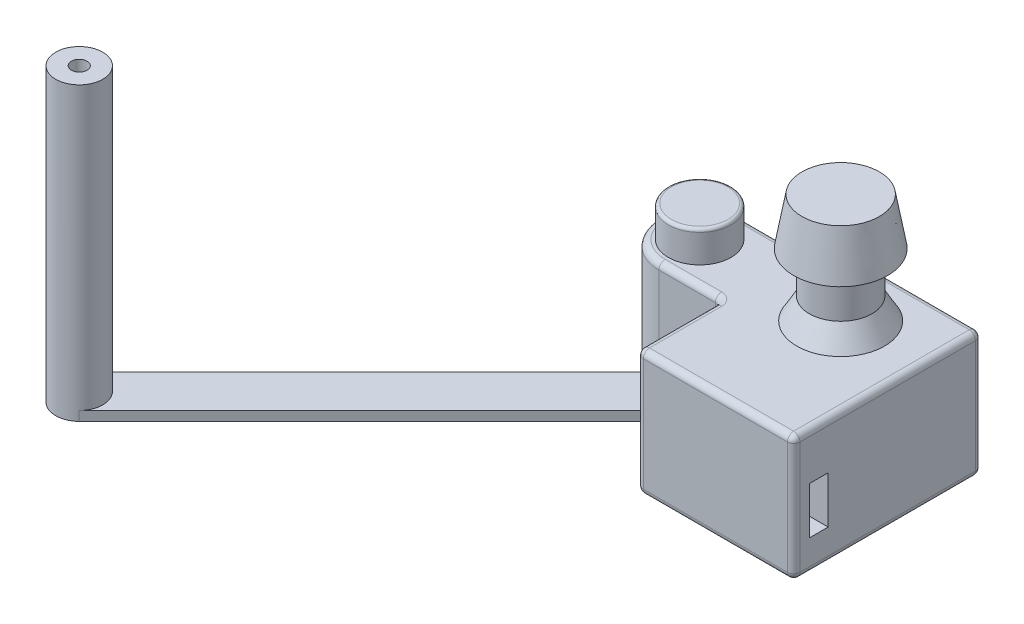
from build123d import *

# Parameters (mm, degrees)
SKETCH1_R                = 10
BOSS_EXTRUDE1_DEPTH      = 20
SKETCH2_W                = 50
SKETCH2_H                = 60
BOSS_EXTRUDE2_DEPTH      = 40
SKETCH3_R                = 10
BOSS_EXTRUDE3_DEPTH      = 30
BOSS_EXTRUDE4_DEPTH      = 10
BOSS_EXTRUDE4_DEPTH_BACK = 30
SKETCH3_2_R              = 10
SKETCH4_R                = 15
BOSS_EXTRUDE5_DEPTH      = 15
BOSS_EXTRUDE5_TAPER      = 10
SKETCH6_W                = 6
SKETCH6_H                = 15
CUT_EXTRUDE1_DEPTH       = 15
SKETCH7_W                = 2
SKETCH7_H                = 14
BOSS_EXTRUDE6_DEPTH      = 12
CHAMFER1_SIZE            = 4
CHAMFER1_SIZE2           = 6.92820323
FILLET1_R                = 1
FILLET2_R                = 2
FILLET3_R                = 2
SKETCH8_R                = 7.5
BOSS_EXTRUDE7_DEPTH      = 15
SKETCH9_R                = 7.5
BOSS_EXTRUDE8_DEPTH      = 3
SKETCH10_R               = 7.5
BOSS_EXTRUDE9_DEPTH      = 90


with BuildPart() as part:
    # Sketch1 → Boss-Extrude1 (new body)
    with BuildSketch(Plane(origin=(0, 0, 0), x_dir=(1, 0, 0), z_dir=(0, 1, 0))):
        Circle(SKETCH1_R)
    extrude(amount=BOSS_EXTRUDE1_DEPTH)

    # Sketch2 → Boss-Extrude2 (add)
    with BuildSketch(Plane.XZ):
        with Locations((0, 10)):
            Rectangle(SKETCH2_W, SKETCH2_H)
    extrude(amount=BOSS_EXTRUDE2_DEPTH)

    # Sketch3 → Boss-Extrude3 (add)
    with BuildSketch(Plane(origin=(0, 0, 0), x_dir=(1, 0, 0), z_dir=(0, 1, 0))):
        with BuildLine():
            Line((-45, -13), (-25, -13))
            Line((-25, -13), (-25, 13))
            Line((-25, 13), (-45, 13))
            ThreePointArc((-45, 13), (-58, 0), (-45, -13))
        make_face()
        with Locations((-45, 0)):
            Circle(SKETCH3_R, mode=Mode.SUBTRACT)
    extrude(amount=-BOSS_EXTRUDE3_DEPTH)

    # Sketch3_2 → Boss-Extrude4 (add, two sides: drawn at the far end of the back side and taken through both)
    with BuildSketch(Plane(origin=(0, 0, 0), x_dir=(1, 0, 0), z_dir=(0, 1, 0)).offset(-BOSS_EXTRUDE4_DEPTH_BACK)):
        with Locations((-45, 0)):
            Circle(SKETCH3_2_R)
    extrude(amount=BOSS_EXTRUDE4_DEPTH + BOSS_EXTRUDE4_DEPTH_BACK)

    # Sketch6 → Cut-Extrude1 (cut)
    with BuildSketch(Plane.ZY.offset(25)):
        with Locations((32, -22.5)):
            Rectangle(SKETCH6_W, SKETCH6_H)
    cut_extrude1 = extrude(amount=-CUT_EXTRUDE1_DEPTH, mode=Mode.SUBTRACT)

    # Sketch7 → Boss-Extrude6 (add)
    with BuildSketch(Plane.ZY.offset(10)):
        with Locations((33.5, -22.5)):
            Rectangle(SKETCH7_W, SKETCH7_H)
    boss_extrude6 = extrude(amount=BOSS_EXTRUDE6_DEPTH)

    # Chamfer1
    chamfer1_edges = [part.edges().sort_by_distance(p)[0] for p in [
        (-10, 0, 0),
    ]]
    chamfer1_side = [part.faces().sort_by_distance(p)[0] for p in [
        (-5.534557326, 0, 9.502252838),
    ]]
    chamfer(chamfer1_edges, length=CHAMFER1_SIZE, length2=CHAMFER1_SIZE2, reference=chamfer1_side[0])

    # Fillet1
    fillet1_edges = [part.edges().sort_by_distance(p)[0] for p in [
        (-55, 10, 0),
    ]]
    fillet(fillet1_edges, radius=FILLET1_R)

    # Fillet2
    fillet2_edges = [part.edges().sort_by_distance(p)[0] for p in [
        (25, -20, 40),
        (-25, -20, 40),
        (-25, -15, -13),
        (-25, -20, -20),
        (25, -20, -20),
        (-25, -15, 13),
    ]]
    fillet(fillet2_edges, radius=FILLET2_R)

    # Fillet3
    fillet3_edges = [part.edges().sort_by_distance(p)[0] for p in [
        (-24.414213562, -40, 39.414213562),
        (0, -40, 40),
        (24.414213562, -40, 39.414213562),
        (25, -40, 10),
        (24.414213562, -40, -19.414213562),
        (0, -40, -20),
        (-24.414213562, -40, -19.414213562),
        (-58, 0, 0),
        (-36, 0, -13),
        (-25.585786438, 0, -13.585786438),
        (-25, 0, -16.5),
        (-24.414213562, 0, -19.414213562),
        (0, 0, -20),
        (24.414213562, 0, -19.414213562),
        (25, 0, 10),
        (24.414213562, 0, 39.414213562),
        (0, 0, 40),
        (-24.414213562, 0, 39.414213562),
        (-25, 0, 26.5),
        (-25.585786438, 0, 13.585786438),
        (-25, -40, 10),
        (-36, 0, 13),
    ]]
    fillet(fillet3_edges, radius=FILLET3_R)

    # Mirror1: Cut-Extrude1, Boss-Extrude6 across plane
    add(cut_extrude1.mirror(Plane(origin=(0, 0, 0), x_dir=(0, 0, 1), z_dir=(1, 0, 0))), mode=Mode.SUBTRACT)
    add(boss_extrude6.mirror(Plane(origin=(0, 0, 0), x_dir=(0, 0, 1), z_dir=(1, 0, 0))))


with BuildPart() as body_2:
    # Sketch4 → Boss-Extrude5 (new body)
    with BuildSketch(Plane(origin=(0, 20, 0), x_dir=(1, 0, 0), z_dir=(0, 1, 0))):
        Circle(SKETCH4_R)
    extrude(amount=BOSS_EXTRUDE5_DEPTH, taper=BOSS_EXTRUDE5_TAPER)


with BuildPart() as body_3:
    # Sketch8 → Boss-Extrude7 (new body)
    with BuildSketch(Plane.XZ.offset(30)):
        with Locations((-45, 0)):
            Circle(SKETCH8_R)
    extrude(amount=BOSS_EXTRUDE7_DEPTH)

    # Sketch9 → Boss-Extrude8 (add)
    with BuildSketch(Plane.XZ.offset(45)):
        with Locations((-143.994949366, 98.994949366)):
            Circle(SKETCH9_R)
        Polygon((-50.303300859, -5.303300859), (-39.696699141, 5.303300859), (-138.691648507, 104.298250225), (-149.298250225, 93.691648507), align=None)
    extrude(amount=-BOSS_EXTRUDE8_DEPTH)

    # Sketch10 → Boss-Extrude9 (add)
    with BuildSketch(Plane(origin=(0, -42, 0), x_dir=(1, 0, 0), z_dir=(0, 1, 0))):
        with Locations((-143.994949366, -98.994949366)):
            Circle(SKETCH10_R)
    extrude(amount=BOSS_EXTRUDE9_DEPTH)

    # Sketch14 → M6 Tapped Hole1 (revolve, cut)
    with BuildSketch(Plane(origin=(-143.994949366, 48, 98.994949366), x_dir=(0, 0, 1), z_dir=(1, 0, 0))):
        Polygon((0, 0), (0, 17.502151548), (2.5, 16), (2.5, 0), align=None)
    revolve(axis=Axis((-143.994949366, 54.35, 98.994949366), (0, -1, 0)), mode=Mode.SUBTRACT)


solid = Compound([part.part, body_2.part, body_3.part])
